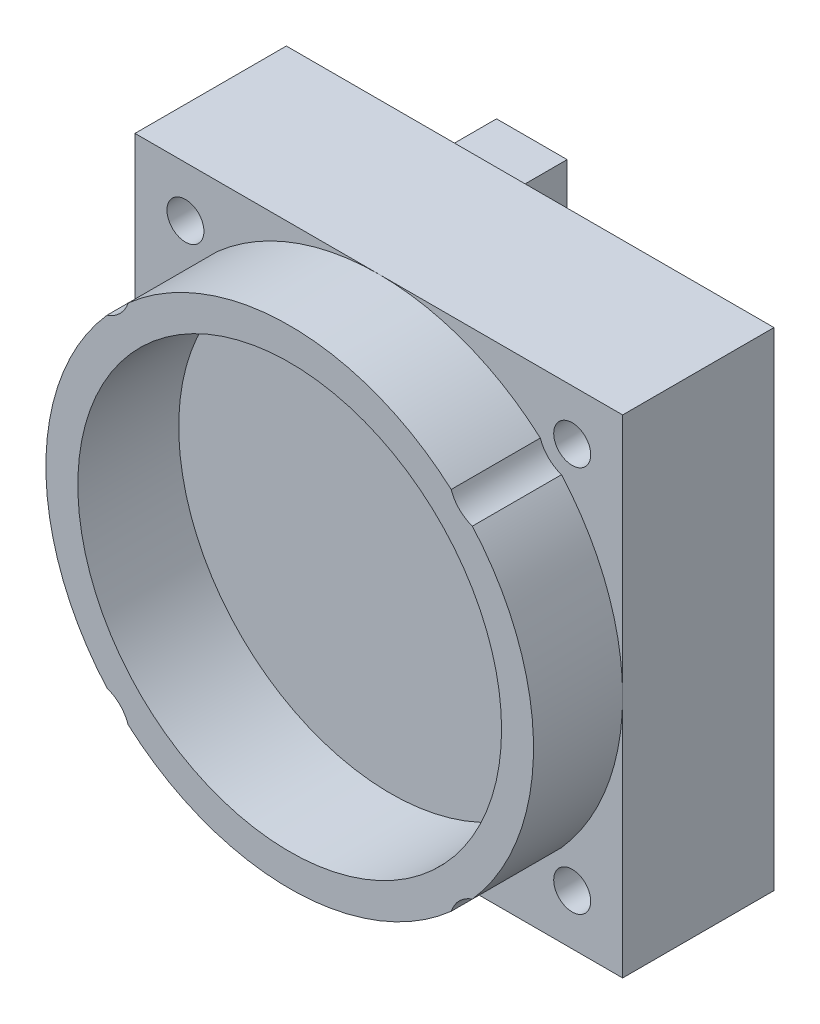
from build123d import *

# Parameters (mm, degrees)
SKETCH1_W             = 29
SKETCH1_H             = 29
BOSS_EXTRUDE1_DEPTH   = 9
SKETCH3_R             = 14.5
BOSS_EXTRUDE2_DEPTH   = 5.3
SKETCH4_R             = 12.6
CUT_EXTRUDE1_DEPTH    = 6
SKETCH5_R             = 1.1
CUT_EXTRUDE2_DEPTH    = 15.3
SKETCH6_R             = 2
CUT_EXTRUDE3_DEPTH    = 6.3
SKETCH7_R             = 1.1
BOSS_EXTRUDE3_DEPTH   = 0.5
SKETCH8_R             = 2
SKETCH8_R_2           = 1.1
BOSS_EXTRUDE4_DEPTH   = 1
BOSS_EXTRUDE4_2_DEPTH = 1
BOSS_EXTRUDE4_3_DEPTH = 1
BOSS_EXTRUDE4_4_DEPTH = 1
SKETCH9_W             = 5.65
SKETCH9_H             = 13
BOSS_EXTRUDE5_DEPTH   = 3.3
SKETCH10_W            = 2.3
SKETCH10_H            = 4.5
SKETCH10_H_2          = 7
CUT_EXTRUDE4_DEPTH    = 3.3
SKETCH11_W            = 4.2
SKETCH11_H            = 3.2
BOSS_EXTRUDE6_DEPTH   = 5
SKETCH12_W            = 7
SKETCH12_H            = 7
SKETCH12_W_2          = 10
SKETCH12_H_2          = 10
BOSS_EXTRUDE7_DEPTH   = 0.5


with BuildPart() as part:
    # Sketch1 → Boss-Extrude1 (new body)
    with BuildSketch(Plane.XY):
        with Locations((14.5, 14.5)):
            Rectangle(SKETCH1_W, SKETCH1_H)
    extrude(amount=BOSS_EXTRUDE1_DEPTH)

    # Sketch3 → Boss-Extrude2 (add)
    with BuildSketch(Plane.XY.offset(9)):
        with Locations((14.5, 14.5)):
            Circle(SKETCH3_R)
    extrude(amount=BOSS_EXTRUDE2_DEPTH)

    # Sketch4 → Cut-Extrude1 (cut)
    with BuildSketch(Plane.XY.offset(14.3)):
        with Locations((14.5, 14.5)):
            Circle(SKETCH4_R)
    extrude(amount=-CUT_EXTRUDE1_DEPTH, mode=Mode.SUBTRACT)

    # Sketch5 → Cut-Extrude2 (cut, through all)
    with BuildSketch(Plane(origin=(0, 0, 0), x_dir=(-1, 0, 0), z_dir=(0, 0, -1))):
        with Locations((-26, 26)):
            Circle(SKETCH5_R)
        with Locations((-3, 26)):
            Circle(SKETCH5_R)
        with Locations((-3, 3)):
            Circle(SKETCH5_R)
        with Locations((-26, 3)):
            Circle(SKETCH5_R)
    extrude(amount=-CUT_EXTRUDE2_DEPTH, mode=Mode.SUBTRACT)

    # Sketch6 → Cut-Extrude3 (cut, through all)
    with BuildSketch(Plane.XY.offset(9)):
        with Locations((3, 26)):
            Circle(SKETCH6_R)
        with Locations((26, 26)):
            Circle(SKETCH6_R)
        with Locations((26, 3)):
            Circle(SKETCH6_R)
        with Locations((3, 3)):
            Circle(SKETCH6_R)
    extrude(amount=CUT_EXTRUDE3_DEPTH, mode=Mode.SUBTRACT)

    # Sketch7 → Boss-Extrude3 (add)
    with BuildSketch(Plane(origin=(0, 0, 0), x_dir=(-1, 0, 0), z_dir=(0, 0, -1))):
        Polygon((-28, 28), (-1, 28), (-1, 21), (-5.65, 21), (-5.65, 8), (-1, 8), (-1, 1), (-28, 1), align=None)
        with Locations((-26, 3)):
            Circle(SKETCH7_R, mode=Mode.SUBTRACT)
        with Locations((-3, 3)):
            Circle(SKETCH7_R, mode=Mode.SUBTRACT)
        with Locations((-3, 26)):
            Circle(SKETCH7_R, mode=Mode.SUBTRACT)
        with Locations((-26, 26)):
            Circle(SKETCH7_R, mode=Mode.SUBTRACT)
    extrude(amount=BOSS_EXTRUDE3_DEPTH)

    # Sketch11 → Boss-Extrude6 (add)
    with BuildSketch(Plane(origin=(0, 0, -0.5), x_dir=(-1, 0, 0), z_dir=(0, 0, -1))):
        with Locations((-9.1, 24.4)):
            Rectangle(SKETCH11_W, SKETCH11_H)
    extrude(amount=BOSS_EXTRUDE6_DEPTH)

    # Sketch12 → Boss-Extrude7 (add)
    with BuildSketch(Plane(origin=(0, 0, -0.5), x_dir=(-1, 0, 0), z_dir=(0, 0, -1))):
        with Locations((-18.7, 22.5)):
            Rectangle(SKETCH12_W, SKETCH12_H)
        with Locations((-17.2, 11)):
            Rectangle(SKETCH12_W_2, SKETCH12_H_2)
    extrude(amount=BOSS_EXTRUDE7_DEPTH)


with BuildPart() as body_2:
    # Sketch8 → Boss-Extrude4 (new body)
    with BuildSketch(Plane(origin=(0, 0, 0), x_dir=(-1, 0, 0), z_dir=(0, 0, -1))):
        with Locations((-26, 26)):
            Circle(SKETCH8_R)
        with Locations((-26, 26)):
            Circle(SKETCH8_R_2, mode=Mode.SUBTRACT)
    extrude(amount=BOSS_EXTRUDE4_DEPTH)


with BuildPart() as body_3:
    # Sketch8 → Boss-Extrude4 2 (new body)
    with BuildSketch(Plane(origin=(0, 0, 0), x_dir=(-1, 0, 0), z_dir=(0, 0, -1))):
        with Locations((-3, 26)):
            Circle(SKETCH8_R)
        with Locations((-3, 26)):
            Circle(SKETCH8_R_2, mode=Mode.SUBTRACT)
    extrude(amount=BOSS_EXTRUDE4_2_DEPTH)


with BuildPart() as body_4:
    # Sketch8 → Boss-Extrude4 3 (new body)
    with BuildSketch(Plane(origin=(0, 0, 0), x_dir=(-1, 0, 0), z_dir=(0, 0, -1))):
        with Locations((-26, 3)):
            Circle(SKETCH8_R)
        with Locations((-26, 3)):
            Circle(SKETCH8_R_2, mode=Mode.SUBTRACT)
    extrude(amount=BOSS_EXTRUDE4_3_DEPTH)


with BuildPart() as body_5:
    # Sketch8 → Boss-Extrude4 4 (new body)
    with BuildSketch(Plane(origin=(0, 0, 0), x_dir=(-1, 0, 0), z_dir=(0, 0, -1))):
        with Locations((-3, 3)):
            Circle(SKETCH8_R)
        with Locations((-3, 3)):
            Circle(SKETCH8_R_2, mode=Mode.SUBTRACT)
    extrude(amount=BOSS_EXTRUDE4_4_DEPTH)


with BuildPart() as body_6:
    # Sketch9 → Boss-Extrude5 (new body)
    with BuildSketch(Plane(origin=(0, 0, 0), x_dir=(-1, 0, 0), z_dir=(0, 0, -1))):
        with Locations((-2.825, 14.5)):
            Rectangle(SKETCH9_W, SKETCH9_H)
    extrude(amount=BOSS_EXTRUDE5_DEPTH)

    # Sketch10 → Cut-Extrude4 (cut)
    with BuildSketch(Plane.ZY):
        with Locations((-1.65, 18.25)):
            Rectangle(SKETCH10_W, SKETCH10_H)
        with Locations((-1.65, 12)):
            Rectangle(SKETCH10_W, SKETCH10_H_2)
    extrude(amount=-CUT_EXTRUDE4_DEPTH, mode=Mode.SUBTRACT)


solid = Compound([part.part, body_2.part, body_3.part, body_4.part, body_5.part, body_6.part])
